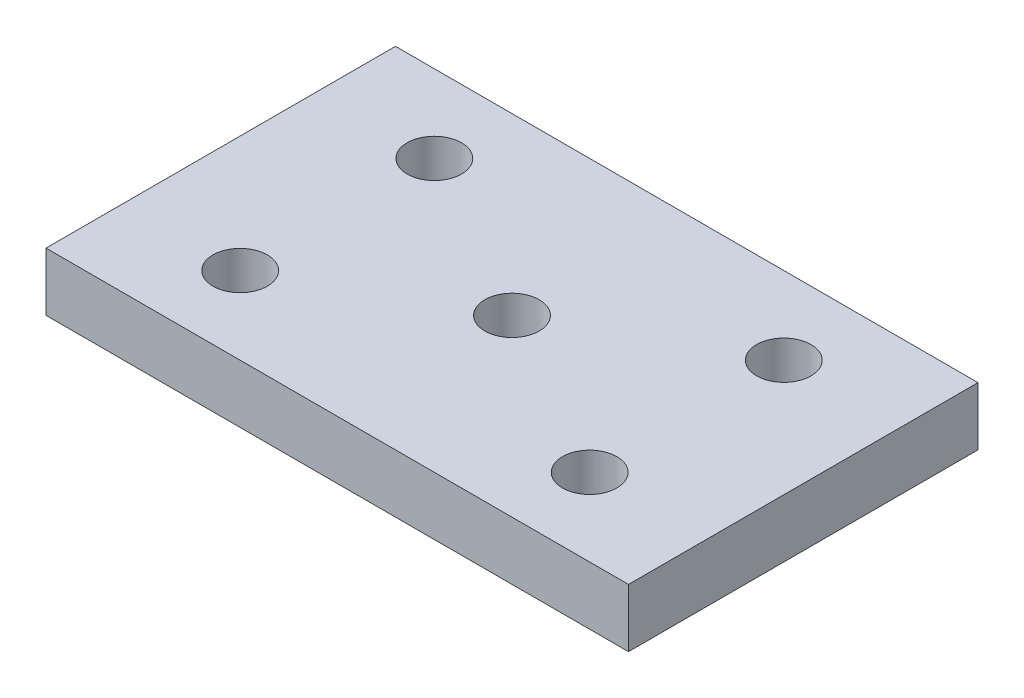
from build123d import *

# Parameters (mm, degrees)
SKETCH1_W           = 30
SKETCH1_H           = 18
SKETCH1_R           = 1.4
BOSS_EXTRUDE1_DEPTH = 3


with BuildPart() as part:
    # Sketch1 → Boss-Extrude1 (new body)
    with BuildSketch(Plane(origin=(0, 0, 0), x_dir=(1, 0, 0), z_dir=(0, 1, 0))):
        with Locations((15, 9)):
            Rectangle(SKETCH1_W, SKETCH1_H)
        with Locations((6, 4)):
            Circle(SKETCH1_R, mode=Mode.SUBTRACT)
        with Locations((24, 4)):
            Circle(SKETCH1_R, mode=Mode.SUBTRACT)
        with Locations((24, 14)):
            Circle(SKETCH1_R, mode=Mode.SUBTRACT)
        with Locations((6, 14)):
            Circle(SKETCH1_R, mode=Mode.SUBTRACT)
        with Locations((15, 9)):
            Circle(SKETCH1_R, mode=Mode.SUBTRACT)
    extrude(amount=BOSS_EXTRUDE1_DEPTH)


solid = part.part
